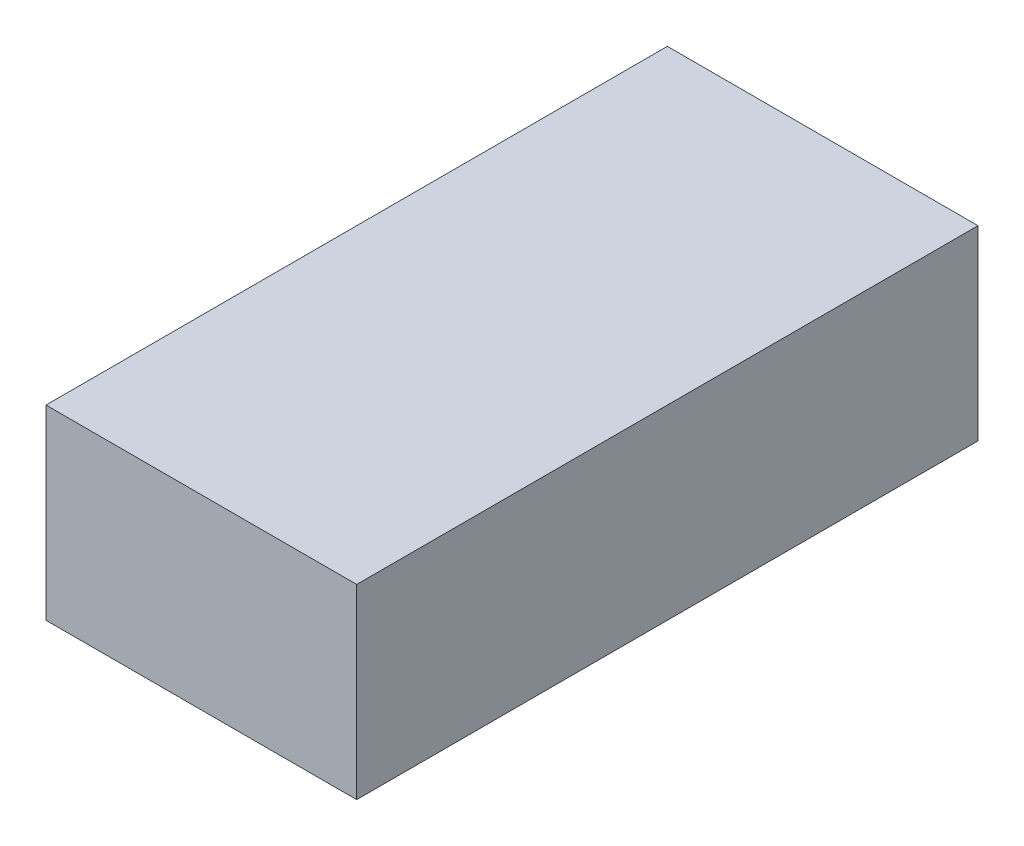
from build123d import *

# Parameters (mm, degrees)
BOSS_EXTRUDE1_DEPTH = 69
SKETCH4_W           = 15
SKETCH4_H           = 124.7
BOSS_EXTRUDE2_DEPTH = 61.9
BOSS_EXTRUDE3_DEPTH = 20.4
FILLET1_R           = 10
SKETCH6_W           = 10000
SKETCH6_H           = 3000
BOSS_EXTRUDE4_DEPTH = 2500


with BuildPart() as part:
    # Sketch2 → Boss-Extrude1 (new body, symmetric)
    with BuildSketch(Plane(origin=(0, 0, 0), x_dir=(0, 0, -1), z_dir=(1, 0, 0))):
        with BuildLine():
            Line((-262.793626597, 0), (0, 0))
            Line((0, 0), (139.7, 0))
            Line((139.7, 0), (139.7, 81.9))
            Line((139.7, 81.9), (124.7, 81.9))
            Line((124.7, 81.9), (124.7, 20))
            Line((124.7, 20), (0, 20))
            Line((0, 20), (0, 133.7))
            Line((0, 133.7), (-115, 133.7))
            Line((-115, 133.7), (-171.193830238, 94.352656466))
            Line((-171.193830238, 94.352656466), (-262.793626597, 81.479144628))
            Line((-262.793626597, 81.479144628), (-262.793626597, 31.479144628))
            ThreePointArc((-262.793626597, 31.479144628), (-272.644060375, 15.739572314), (-262.793626597, 0))
        make_face()
    extrude(amount=BOSS_EXTRUDE1_DEPTH, both=True)

    # Sketch4 → Boss-Extrude2 (add)
    with BuildSketch(Plane(origin=(0, 20, 0), x_dir=(1, 0, 0), z_dir=(0, 1, 0))):
        with Locations((61.5, 62.35)):
            Rectangle(SKETCH4_W, SKETCH4_H)
    boss_extrude2 = extrude(amount=BOSS_EXTRUDE2_DEPTH)

    # Mirror1: Boss-Extrude2 across plane
    add(boss_extrude2.mirror(Plane(origin=(0, 0, 0), x_dir=(0, 0, 1), z_dir=(1, 0, 0))))

    # Sketch5 → Boss-Extrude3 (add)
    with BuildSketch(Plane(origin=(69, 0, 0), x_dir=(0, 0, -1), z_dir=(1, 0, 0))):
        with BuildLine():
            Line((-224.944060375, 0), (-160.344060375, 0))
            ThreePointArc((-160.344060375, 0), (-192.644060375, -32.3), (-224.944060375, 0))
        make_face()
        with BuildLine():
            Line((28.055939625, 0), (92.655939625, 0))
            ThreePointArc((92.655939625, 0), (60.355939625, -32.3), (28.055939625, 0))
        make_face()
    boss_extrude3 = extrude(amount=-BOSS_EXTRUDE3_DEPTH)

    # Mirror2: Boss-Extrude3 across plane
    add(boss_extrude3.mirror(Plane(origin=(0, 0, 0), x_dir=(0, 0, 1), z_dir=(1, 0, 0))))

    # Fillet1
    fillet1_edges = [part.edges().sort_by_distance(p)[0] for p in [
        (0, 31.479144628, 262.793626597),
        (0, 81.479144628, 262.793626597),
        (0, 94.352656466, 171.193830238),
        (0, 133.7, 115),
        (0, 133.7, 0),
    ]]
    fillet(fillet1_edges, radius=FILLET1_R)


with BuildPart() as body_2:
    # Sketch6 → Boss-Extrude4 (new body, symmetric)
    with BuildSketch(Plane(origin=(0, 0, 0), x_dir=(0, 0, -1), z_dir=(1, 0, 0))):
        with Locations((2727.48649749, 1467.7)):
            Rectangle(SKETCH6_W, SKETCH6_H)
    extrude(amount=BOSS_EXTRUDE4_DEPTH, both=True)


solid = Compound([part.part, body_2.part])
